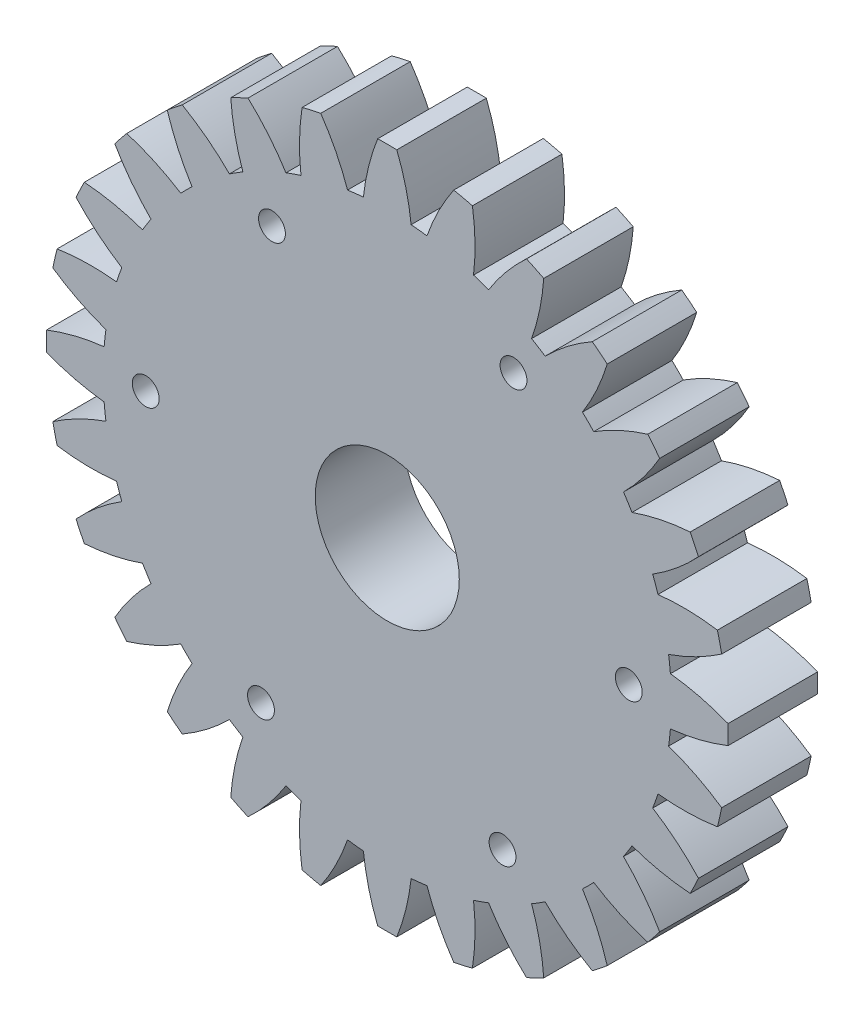
from build123d import *

# Parameters (mm, degrees)
SKETCH1_R           = 4.025
SKETCH1_R_2         = 0.75
BOSS_EXTRUDE1_DEPTH = 5


with BuildPart() as part:
    # Sketch1 → Boss-Extrude1 (new body)
    with BuildSketch(Plane.XY.offset(5)):
        with BuildLine():
            ThreePointArc((-4.820868329, 15.125305073), (-5.243180109, 14.984147869), (-5.661366831, 14.831201927))
            ThreePointArc((-5.661366831, 14.831201927), (-6.63581244, 16.180559962), (-7.780863095, 17.388521199))
            ThreePointArc((-7.780863095, 17.388521199), (-8.26548523, 17.163456934), (-8.743604518, 16.924889365))
            ThreePointArc((-8.743604518, 16.924889365), (-8.513109799, 15.276501202), (-8.065696106, 13.673337973))
            ThreePointArc((-8.065696106, 13.673337973), (-8.446009215, 13.441746663), (-8.819677449, 13.199580095))
            ThreePointArc((-8.819677449, 13.199580095), (-10.069952083, 14.29827236), (-11.455090589, 15.221149746))
            ThreePointArc((-11.455090589, 15.221149746), (-11.877480725, 14.893889741), (-12.290526286, 14.554912009))
            ThreePointArc((-12.290526286, 14.554912009), (-11.699009678, 12.999142279), (-10.906076201, 11.535732612))
            ThreePointArc((-10.906076201, 11.535732612), (-11.225320151, 11.225320151), (-11.535732612, 10.906076201))
            ThreePointArc((-11.535732612, 10.906076201), (-12.999142279, 11.699009678), (-14.554912009, 12.290526286))
            ThreePointArc((-14.554912009, 12.290526286), (-14.893889741, 11.877480725), (-15.221149746, 11.455090589))
            ThreePointArc((-15.221149746, 11.455090589), (-14.29827236, 10.069952083), (-13.199580095, 8.819677449))
            ThreePointArc((-13.199580095, 8.819677449), (-13.441746663, 8.446009215), (-13.673337973, 8.065696106))
            ThreePointArc((-13.673337973, 8.065696106), (-15.276501202, 8.513109799), (-16.924889365, 8.743604518))
            ThreePointArc((-16.924889365, 8.743604518), (-17.163456934, 8.26548523), (-17.388521199, 7.780863095))
            ThreePointArc((-17.388521199, 7.780863095), (-16.180559962, 6.63581244), (-14.831201927, 5.661366831))
            ThreePointArc((-14.831201927, 5.661366831), (-14.984147869, 5.243180109), (-15.125305073, 4.820868329))
            ThreePointArc((-15.125305073, 4.820868329), (-16.787832566, 4.900327047), (-18.446182096, 4.758241909))
            ThreePointArc((-18.446182096, 4.758241909), (-18.572376727, 4.239023792), (-18.683959592, 3.716470634))
            ThreePointArc((-18.683959592, 3.716470634), (-17.251486724, 2.868925453), (-15.719125365, 2.21917164))
            ThreePointArc((-15.719125365, 2.21917164), (-15.775181332, 1.777436058), (-15.818826219, 1.334302083))
            ThreePointArc((-15.818826219, 1.334302083), (-17.457351905, 1.041821436), (-19.042506233, 0.534281182))
            ThreePointArc((-19.042506233, 0.534281182), (-19.05, 0), (-19.042506233, -0.534281182))
            ThreePointArc((-19.042506233, -0.534281182), (-17.457351905, -1.041821436), (-15.818826219, -1.334302083))
            ThreePointArc((-15.818826219, -1.334302083), (-15.775181332, -1.777436058), (-15.719125365, -2.21917164))
            ThreePointArc((-15.719125365, -2.21917164), (-17.251486724, -2.868925453), (-18.683959592, -3.716470634))
            ThreePointArc((-18.683959592, -3.716470634), (-18.572376727, -4.239023792), (-18.446182096, -4.758241909))
            ThreePointArc((-18.446182096, -4.758241909), (-16.787832566, -4.900327047), (-15.125305073, -4.820868329))
            ThreePointArc((-15.125305073, -4.820868329), (-14.984147869, -5.243180109), (-14.831201927, -5.661366831))
            ThreePointArc((-14.831201927, -5.661366831), (-16.180559962, -6.63581244), (-17.388521199, -7.780863095))
            ThreePointArc((-17.388521199, -7.780863095), (-17.163456934, -8.26548523), (-16.924889365, -8.743604518))
            ThreePointArc((-16.924889365, -8.743604518), (-15.276501202, -8.513109799), (-13.673337973, -8.065696106))
            ThreePointArc((-13.673337973, -8.065696106), (-13.441746663, -8.446009215), (-13.199580095, -8.819677449))
            ThreePointArc((-13.199580095, -8.819677449), (-14.29827236, -10.069952083), (-15.221149746, -11.455090589))
            ThreePointArc((-15.221149746, -11.455090589), (-14.893889741, -11.877480725), (-14.554912009, -12.290526286))
            ThreePointArc((-14.554912009, -12.290526286), (-12.999142279, -11.699009678), (-11.535732612, -10.906076201))
            ThreePointArc((-11.535732612, -10.906076201), (-11.225320151, -11.225320151), (-10.906076201, -11.535732612))
            ThreePointArc((-10.906076201, -11.535732612), (-11.699009678, -12.999142279), (-12.290526286, -14.554912009))
            ThreePointArc((-12.290526286, -14.554912009), (-11.877480725, -14.893889741), (-11.455090589, -15.221149746))
            ThreePointArc((-11.455090589, -15.221149746), (-10.069952083, -14.29827236), (-8.819677449, -13.199580095))
            ThreePointArc((-8.819677449, -13.199580095), (-8.446009215, -13.441746663), (-8.065696106, -13.673337973))
            ThreePointArc((-8.065696106, -13.673337973), (-8.513109799, -15.276501202), (-8.743604518, -16.924889365))
            ThreePointArc((-8.743604518, -16.924889365), (-8.26548523, -17.163456934), (-7.780863095, -17.388521199))
            ThreePointArc((-7.780863095, -17.388521199), (-6.63581244, -16.180559962), (-5.661366831, -14.831201927))
            ThreePointArc((-5.661366831, -14.831201927), (-5.243180109, -14.984147869), (-4.820868329, -15.125305073))
            ThreePointArc((-4.820868329, -15.125305073), (-4.900327047, -16.787832566), (-4.758241909, -18.446182096))
            ThreePointArc((-4.758241909, -18.446182096), (-4.239023792, -18.572376727), (-3.716470634, -18.683959592))
            ThreePointArc((-3.716470634, -18.683959592), (-2.868925453, -17.251486724), (-2.21917164, -15.719125365))
            ThreePointArc((-2.21917164, -15.719125365), (-1.777436058, -15.775181332), (-1.334302083, -15.818826219))
            ThreePointArc((-1.334302083, -15.818826219), (-1.041821436, -17.457351905), (-0.534281182, -19.042506233))
            ThreePointArc((-0.534281182, -19.042506233), (0, -19.05), (0.534281182, -19.042506233))
            ThreePointArc((0.534281182, -19.042506233), (1.041821436, -17.457351905), (1.334302083, -15.818826219))
            ThreePointArc((1.334302083, -15.818826219), (1.777436058, -15.775181332), (2.21917164, -15.719125365))
            ThreePointArc((2.21917164, -15.719125365), (2.868925453, -17.251486724), (3.716470634, -18.683959592))
            ThreePointArc((3.716470634, -18.683959592), (4.239023792, -18.572376727), (4.758241909, -18.446182096))
            ThreePointArc((4.758241909, -18.446182096), (4.900327047, -16.787832566), (4.820868329, -15.125305073))
            ThreePointArc((4.820868329, -15.125305073), (5.243180109, -14.984147869), (5.661366831, -14.831201927))
            ThreePointArc((5.661366831, -14.831201927), (6.63581244, -16.180559962), (7.780863095, -17.388521199))
            ThreePointArc((7.780863095, -17.388521199), (8.26548523, -17.163456934), (8.743604518, -16.924889365))
            ThreePointArc((8.743604518, -16.924889365), (8.513109799, -15.276501202), (8.065696106, -13.673337973))
            ThreePointArc((8.065696106, -13.673337973), (8.446009215, -13.441746663), (8.819677449, -13.199580095))
            ThreePointArc((8.819677449, -13.199580095), (10.069952083, -14.29827236), (11.455090589, -15.221149746))
            ThreePointArc((11.455090589, -15.221149746), (11.877480725, -14.893889741), (12.290526286, -14.554912009))
            ThreePointArc((12.290526286, -14.554912009), (11.699009678, -12.999142279), (10.906076201, -11.535732612))
            ThreePointArc((10.906076201, -11.535732612), (11.225320151, -11.225320151), (11.535732612, -10.906076201))
            ThreePointArc((11.535732612, -10.906076201), (12.999142279, -11.699009678), (14.554912009, -12.290526286))
            ThreePointArc((14.554912009, -12.290526286), (14.893889741, -11.877480725), (15.221149746, -11.455090589))
            ThreePointArc((15.221149746, -11.455090589), (14.29827236, -10.069952083), (13.199580095, -8.819677449))
            ThreePointArc((13.199580095, -8.819677449), (13.441746663, -8.446009215), (13.673337973, -8.065696106))
            ThreePointArc((13.673337973, -8.065696106), (15.276501202, -8.513109799), (16.924889365, -8.743604518))
            ThreePointArc((16.924889365, -8.743604518), (17.163456934, -8.26548523), (17.388521199, -7.780863095))
            ThreePointArc((17.388521199, -7.780863095), (16.180559962, -6.63581244), (14.831201927, -5.661366831))
            ThreePointArc((14.831201927, -5.661366831), (14.984147869, -5.243180109), (15.125305073, -4.820868329))
            ThreePointArc((15.125305073, -4.820868329), (16.787832566, -4.900327047), (18.446182096, -4.758241909))
            ThreePointArc((18.446182096, -4.758241909), (18.572376727, -4.239023792), (18.683959592, -3.716470634))
            ThreePointArc((18.683959592, -3.716470634), (17.251486724, -2.868925453), (15.719125365, -2.21917164))
            ThreePointArc((15.719125365, -2.21917164), (15.775181332, -1.777436058), (15.818826219, -1.334302083))
            ThreePointArc((15.818826219, -1.334302083), (17.457351905, -1.041821436), (19.042506233, -0.534281182))
            ThreePointArc((19.042506233, -0.534281182), (19.05, 0), (19.042506233, 0.534281182))
            ThreePointArc((19.042506233, 0.534281182), (17.457351905, 1.041821436), (15.818826219, 1.334302083))
            ThreePointArc((15.818826219, 1.334302083), (15.775181332, 1.777436058), (15.719125365, 2.21917164))
            ThreePointArc((15.719125365, 2.21917164), (17.251486724, 2.868925453), (18.683959592, 3.716470634))
            ThreePointArc((18.683959592, 3.716470634), (18.572376727, 4.239023792), (18.446182096, 4.758241909))
            ThreePointArc((18.446182096, 4.758241909), (16.787832566, 4.900327047), (15.125305073, 4.820868329))
            ThreePointArc((15.125305073, 4.820868329), (14.984147869, 5.243180109), (14.831201927, 5.661366831))
            ThreePointArc((14.831201927, 5.661366831), (16.180559962, 6.63581244), (17.388521199, 7.780863095))
            ThreePointArc((17.388521199, 7.780863095), (17.163456934, 8.26548523), (16.924889365, 8.743604518))
            ThreePointArc((16.924889365, 8.743604518), (15.276501202, 8.513109799), (13.673337973, 8.065696106))
            ThreePointArc((13.673337973, 8.065696106), (13.441746663, 8.446009215), (13.199580095, 8.819677449))
            ThreePointArc((13.199580095, 8.819677449), (14.29827236, 10.069952083), (15.221149746, 11.455090589))
            ThreePointArc((15.221149746, 11.455090589), (14.893889741, 11.877480725), (14.554912009, 12.290526286))
            ThreePointArc((14.554912009, 12.290526286), (12.999142279, 11.699009678), (11.535732612, 10.906076201))
            ThreePointArc((11.535732612, 10.906076201), (11.225320151, 11.225320151), (10.906076201, 11.535732612))
            ThreePointArc((10.906076201, 11.535732612), (11.699009678, 12.999142279), (12.290526286, 14.554912009))
            ThreePointArc((12.290526286, 14.554912009), (11.877480725, 14.893889741), (11.455090589, 15.221149746))
            ThreePointArc((11.455090589, 15.221149746), (10.069952083, 14.29827236), (8.819677449, 13.199580095))
            ThreePointArc((8.819677449, 13.199580095), (8.446009215, 13.441746663), (8.065696106, 13.673337973))
            ThreePointArc((8.065696106, 13.673337973), (8.513109799, 15.276501202), (8.743604518, 16.924889365))
            ThreePointArc((8.743604518, 16.924889365), (8.26548523, 17.163456934), (7.780863095, 17.388521199))
            ThreePointArc((7.780863095, 17.388521199), (6.63581244, 16.180559962), (5.661366831, 14.831201927))
            ThreePointArc((5.661366831, 14.831201927), (5.243180109, 14.984147869), (4.820868329, 15.125305073))
            ThreePointArc((4.820868329, 15.125305073), (4.900327047, 16.787832566), (4.758241909, 18.446182096))
            ThreePointArc((4.758241909, 18.446182096), (4.239023792, 18.572376727), (3.716470634, 18.683959592))
            ThreePointArc((3.716470634, 18.683959592), (2.868925453, 17.251486724), (2.21917164, 15.719125365))
            ThreePointArc((2.21917164, 15.719125365), (1.777436058, 15.775181332), (1.334302083, 15.818826219))
            ThreePointArc((1.334302083, 15.818826219), (1.041821436, 17.457351905), (0.534281182, 19.042506233))
            ThreePointArc((0.534281182, 19.042506233), (0, 19.05), (-0.534281182, 19.042506233))
            ThreePointArc((-0.534281182, 19.042506233), (-1.041821436, 17.457351905), (-1.334302083, 15.818826219))
            ThreePointArc((-1.334302083, 15.818826219), (-1.777436058, 15.775181332), (-2.21917164, 15.719125365))
            ThreePointArc((-2.21917164, 15.719125365), (-2.868925453, 17.251486724), (-3.716470634, 18.683959592))
            ThreePointArc((-3.716470634, 18.683959592), (-4.239023792, 18.572376727), (-4.758241909, 18.446182096))
            ThreePointArc((-4.758241909, 18.446182096), (-4.900327047, 16.787832566), (-4.820868329, 15.125305073))
        make_face()
        Circle(SKETCH1_R, mode=Mode.SUBTRACT)
        with Locations((-6.440492032, 11.864656016)):
            Circle(SKETCH1_R_2, mode=Mode.SUBTRACT)
        with Locations((7.054847501, 11.509957721)):
            Circle(SKETCH1_R_2, mode=Mode.SUBTRACT)
        with Locations((13.495339533, -0.354698296)):
            Circle(SKETCH1_R_2, mode=Mode.SUBTRACT)
        with Locations((6.440492032, -11.864656016)):
            Circle(SKETCH1_R_2, mode=Mode.SUBTRACT)
        with Locations((-7.054847501, -11.509957721)):
            Circle(SKETCH1_R_2, mode=Mode.SUBTRACT)
        with Locations((-13.495339533, 0.354698296)):
            Circle(SKETCH1_R_2, mode=Mode.SUBTRACT)
    extrude(amount=-BOSS_EXTRUDE1_DEPTH)


solid = part.part
